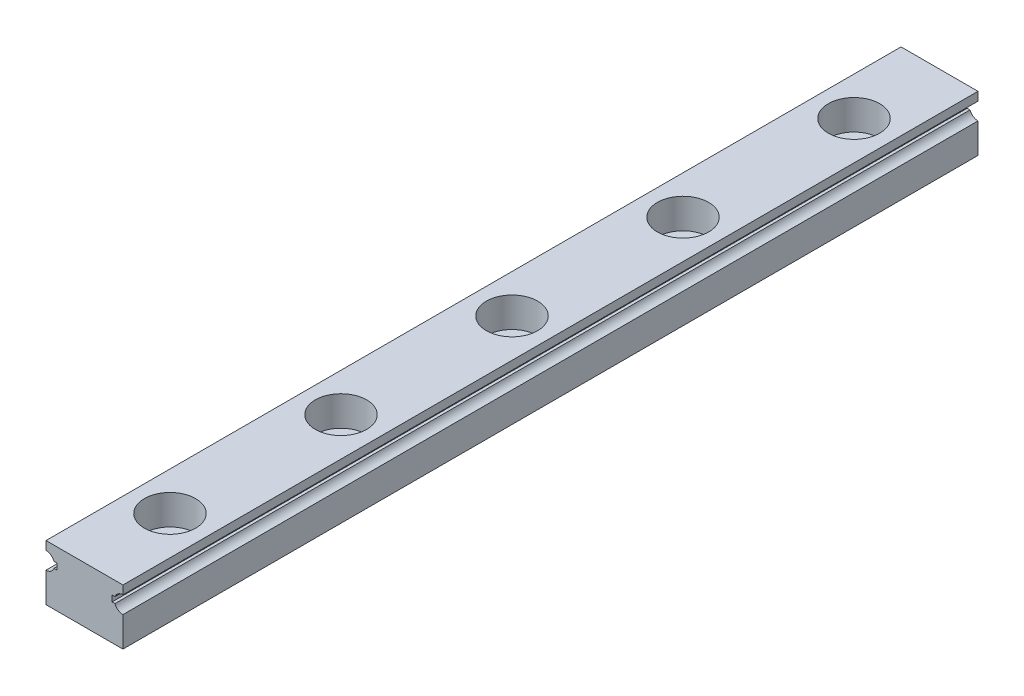
from build123d import *

# Parameters (mm, degrees)
EXTRUDE1_DEPTH  = 100
SKETCH2_R       = 3
EXTRUDE2_DEPTH  = 3.5
SKETCH_R        = 1.75
EXTRUDE3_DEPTH  = 101.312013239
LPATTERN1_COUNT = 13
LPATTERN1_PITCH = 20


with BuildPart() as part:
    # Sketch1 → Extrude1 (new body)
    with BuildSketch(Plane.XY):
        with BuildLine():
            Line((-4.5, -3.25), (4.5, -3.25))
            Line((4.5, -3.25), (4.5, 0.25))
            ThreePointArc((4.5, 0.25), (3.93077967, 0.427814974), (3.563991137, 0.898023568))
            Line((3.563991137, 0.898023568), (3.235073025, 0.898023568))
            Line((3.235073025, 0.898023568), (3.235073025, 1.601976432))
            Line((3.235073025, 1.601976432), (3.563991137, 1.601976432))
            ThreePointArc((3.563991137, 1.601976432), (3.93077967, 2.072185026), (4.5, 2.25))
            Line((4.5, 2.25), (4.5, 3.25))
            Line((4.5, 3.25), (-4.5, 3.25))
            Line((-4.5, 3.25), (-4.5, 2.25))
            ThreePointArc((-4.5, 2.25), (-3.93077967, 2.072185026), (-3.563991137, 1.601976432))
            Line((-3.563991137, 1.601976432), (-3.235073025, 1.601976432))
            Line((-3.235073025, 1.601976432), (-3.235073025, 0.898023568))
            Line((-3.235073025, 0.898023568), (-3.563991137, 0.898023568))
            ThreePointArc((-3.563991137, 0.898023568), (-3.93077967, 0.427814974), (-4.5, 0.25))
            Line((-4.5, 0.25), (-4.5, -3.25))
        make_face()
    extrude(amount=EXTRUDE1_DEPTH)

    # Sketch2 → Extrude2 (cut)
    with BuildSketch(Plane(origin=(0, 3.25, 0), x_dir=(1, 0, 0), z_dir=(0, 1, 0))):
        with Locations((0, -10)):
            Circle(SKETCH2_R)
    extrude2 = extrude(amount=-EXTRUDE2_DEPTH, mode=Mode.SUBTRACT)

    # Sketch → Extrude3 (cut, through all)
    with BuildSketch(Plane(origin=(0, 3.25, 0), x_dir=(1, 0, 0), z_dir=(0, 1, 0))):
        with Locations((0, -10)):
            Circle(SKETCH_R)
    extrude3 = extrude(amount=-EXTRUDE3_DEPTH, mode=Mode.SUBTRACT)

    # LPattern1: Extrude2, Extrude3 ×13
    with Locations(*[(0, 0, i * LPATTERN1_PITCH) for i in range(1, LPATTERN1_COUNT)]):
        add(extrude2, mode=Mode.SUBTRACT)
        add(extrude3, mode=Mode.SUBTRACT)


solid = part.part
